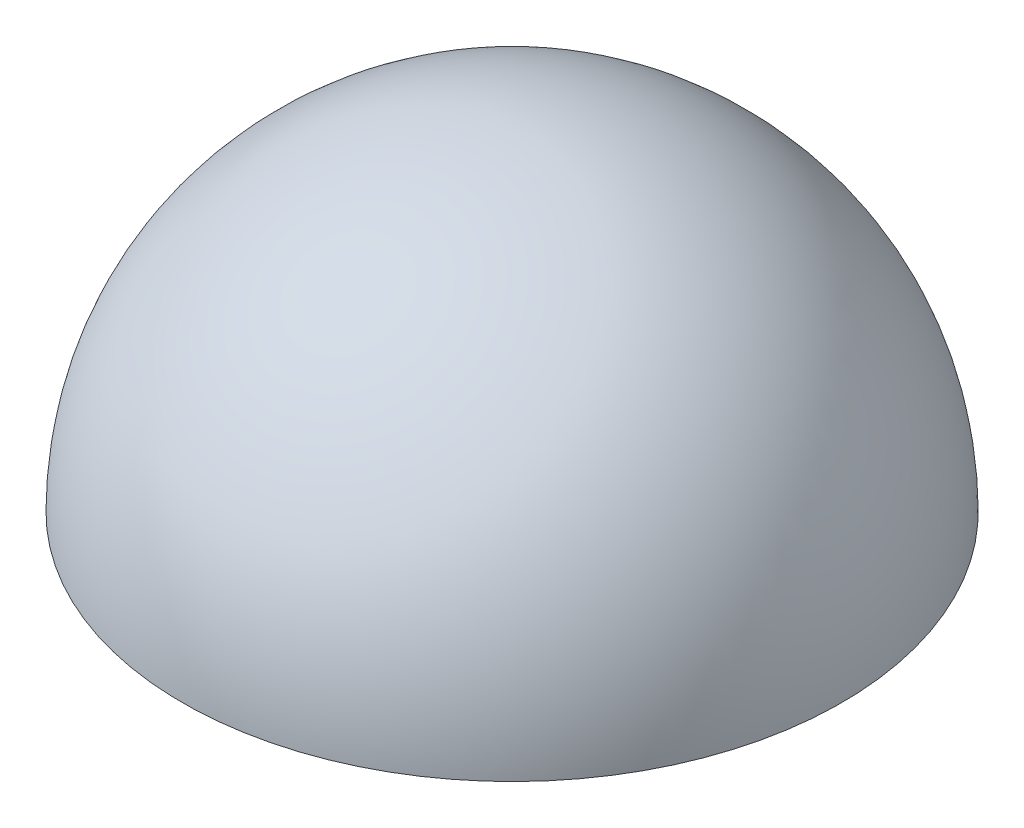
from build123d import *


with BuildPart() as part:
    # Sketch1 → Revolve1 (revolve)
    with BuildSketch(Plane(origin=(0, 0, 0), x_dir=(0, 0, -1), z_dir=(1, 0, 0))):
        with BuildLine():
            Line((-7.033598616, -54.966270669), (-3.533598616, -54.966270669))
            ThreePointArc((-3.533598616, -54.966270669), (-4.558724882, -52.491396935), (-7.033598616, -51.466270669))
            Line((-7.033598616, -51.466270669), (-7.033598616, -54.966270669))
        make_face()
    revolve(axis=Axis((0, -54.966270669, 7.033598616), (0, 1, 0)))


solid = part.part
